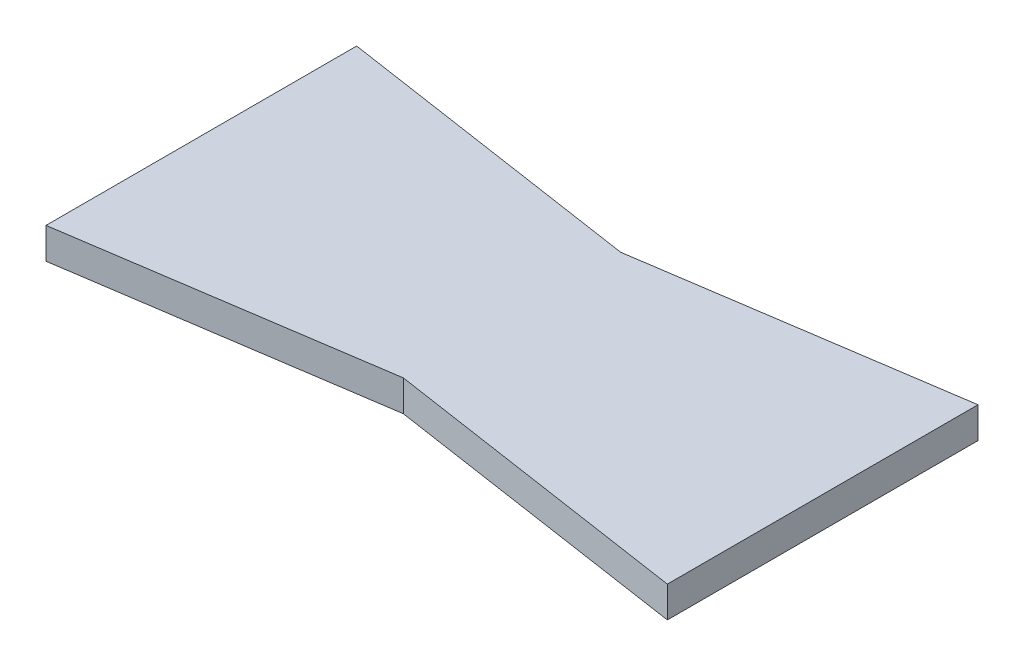
from build123d import *

# Parameters (mm, degrees)
BOSS_EXTRUDE1_DEPTH = 4


with BuildPart() as part:
    # Sketch1 → Boss-Extrude1 (new body)
    with BuildSketch(Plane(origin=(0, 0, 0), x_dir=(1, 0, 0), z_dir=(0, 1, 0))):
        Polygon((-33.992673993, 22.124542125), (6.007326007, 16.124542125), (46.007326007, 22.124542125), (46.007326007, -17.875457875), (6.007326007, -11.875457875), (-33.992673993, -17.875457875), align=None)
    extrude(amount=BOSS_EXTRUDE1_DEPTH)


solid = part.part
